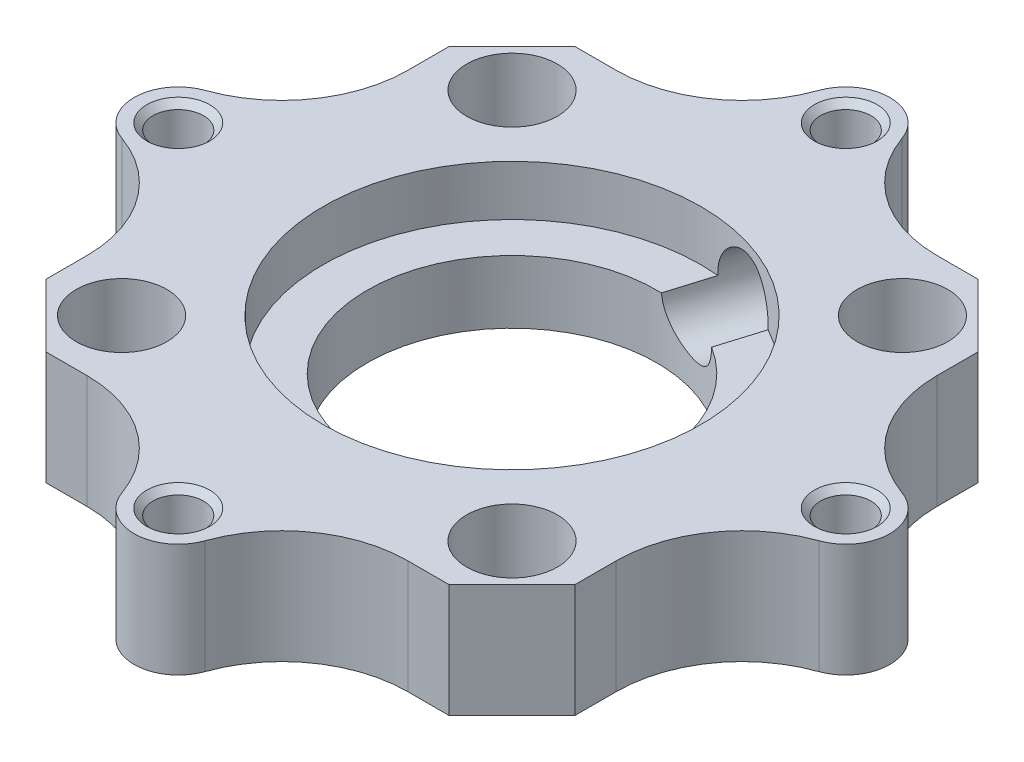
from build123d import *

# Parameters (mm, degrees)
SKETCH1_W               = 60
SKETCH1_H               = 60
SKETCH1_R               = 11.5
BOSS_EXTRUDE1_DEPTH     = 5
CUT_EXTRUDE1_DEPTH      = 10
SKETCH3_R               = 3.6
CUT_EXTRUDE2_DEPTH      = 3
SKETCH4_R               = 1.6
CUT_EXTRUDE3_DEPTH      = 3
SKETCH5_R               = 2
CUT_EXTRUDE4_DEPTH      = 6
CUT_EXTRUDE5_DEPTH      = 6
CHAMFER1_SIZE           = 5
FILLET1_R               = 10
SKETCH7_R               = 2
SKETCH7_R_2             = 3.6
SKETCH7_R_3             = 11.5
BOSS_EXTRUDE2_DEPTH     = 4
SKETCH8_R               = 15
CUT_EXTRUDE6_DEPTH      = 4
SKETCH10_R              = 3
CUT_EXTRUDE7_DEPTH      = 10
CUT_EXTRUDE7_DEPTH_BACK = 16
CHAMFER2_SIZE           = 0.5


with BuildPart() as part:
    # Sketch1 → Boss-Extrude1 (new body)
    with BuildSketch(Plane(origin=(0, 0, 0), x_dir=(1, 0, 0), z_dir=(0, 1, 0))):
        Rectangle(SKETCH1_W, SKETCH1_H)
        Circle(SKETCH1_R, mode=Mode.SUBTRACT)
    extrude(amount=BOSS_EXTRUDE1_DEPTH)

    # Sketch2 → Cut-Extrude1 (cut)
    with BuildSketch(Plane(origin=(0, 5, 0), x_dir=(1, 0, 0), z_dir=(0, 1, 0))):
        with BuildLine():
            Line((-30, 30), (-30, 0))
            ThreePointArc((-30, 0), (-21.21320342, 21.213203451), (4.3e-08, 30))
            Line((4.3e-08, 30), (-30, 30))
        make_face()
        with BuildLine():
            ThreePointArc((4.3e-08, 30), (21.213203451, 21.21320342), (30, 0))
            Line((30, 0), (30, 30))
            Line((30, 30), (4.3e-08, 30))
        make_face()
        with BuildLine():
            Line((0, -30), (30, -30))
            Line((30, -30), (30, 0))
            ThreePointArc((30, 0), (21.213203436, -21.213203436), (0, -30))
        make_face()
        with BuildLine():
            Line((-30, -30), (0, -30))
            ThreePointArc((0, -30), (-21.213203436, -21.213203436), (-30, 0))
            Line((-30, 0), (-30, -30))
        make_face()
    extrude(amount=-CUT_EXTRUDE1_DEPTH, mode=Mode.SUBTRACT)

    # Sketch3 → Cut-Extrude2 (cut)
    with BuildSketch(Plane(origin=(0, 5, 0), x_dir=(1, 0, 0), z_dir=(0, 1, 0))):
        with Locations((-15.5, 15.5)):
            Circle(SKETCH3_R)
        with Locations((15.5, 15.5)):
            Circle(SKETCH3_R)
        with Locations((15.5, -15.5)):
            Circle(SKETCH3_R)
        with Locations((-15.5, -15.5)):
            Circle(SKETCH3_R)
    extrude(amount=-CUT_EXTRUDE2_DEPTH, mode=Mode.SUBTRACT)

    # Sketch4 → Cut-Extrude3 (cut)
    with BuildSketch(Plane(origin=(0, 2, 0), x_dir=(1, 0, 0), z_dir=(0, 1, 0))):
        with Locations((-15.5, 15.5)):
            Circle(SKETCH4_R)
        with Locations((15.5, 15.5)):
            Circle(SKETCH4_R)
        with Locations((15.5, -15.5)):
            Circle(SKETCH4_R)
        with Locations((-15.5, -15.5)):
            Circle(SKETCH4_R)
    extrude(amount=-CUT_EXTRUDE3_DEPTH, mode=Mode.SUBTRACT)

    # Sketch5 → Cut-Extrude4 (cut, through all)
    with BuildSketch(Plane(origin=(0, 5, 0), x_dir=(1, 0, 0), z_dir=(0, 1, 0))):
        with Locations((-26.5, 0)):
            Circle(SKETCH5_R)
        with Locations((0, 26.5)):
            Circle(SKETCH5_R)
        with Locations((26.5, 0)):
            Circle(SKETCH5_R)
        with Locations((0, -26.5)):
            Circle(SKETCH5_R)
    extrude(amount=-CUT_EXTRUDE4_DEPTH, mode=Mode.SUBTRACT)

    # Sketch6 → Cut-Extrude5 (cut, through all)
    with BuildSketch(Plane(origin=(0, 5, 0), x_dir=(1, 0, 0), z_dir=(0, 1, 0))):
        with BuildLine():
            ThreePointArc((-3.5, 26.5), (-2.474873736, 28.974873732), (-5e-09, 30))
            ThreePointArc((-5e-09, 30), (-21.213203437, 21.213203434), (-30, 1e-09))
            ThreePointArc((-30, 1e-09), (-28.974873734, 2.474873735), (-26.5, 3.5))
            Line((-26.5, 3.5), (-21, 3.5))
            Line((-21, 3.5), (-21, 21))
            Line((-21, 21), (-3.5, 21))
            Line((-3.5, 21), (-3.5, 26.5))
        make_face()
        with BuildLine():
            Line((3.5, 26.5), (3.5, 21))
            Line((3.5, 21), (21, 21))
            Line((21, 21), (21, 3.5))
            Line((21, 3.5), (26.5, 3.5))
            ThreePointArc((26.5, 3.5), (28.974873734, 2.474873734), (30, 0))
            ThreePointArc((30, 0), (21.213203434, 21.213203438), (-5e-09, 30))
            ThreePointArc((-5e-09, 30), (2.474873732, 28.974873736), (3.5, 26.5))
        make_face()
        with BuildLine():
            ThreePointArc((-26.5, -3.5), (-28.974873735, -2.474873734), (-30, 1e-09))
            ThreePointArc((-30, 1e-09), (-21.213203436, -21.213203435), (0, -30))
            ThreePointArc((0, -30), (-2.474873734, -28.974873734), (-3.5, -26.5))
            Line((-3.5, -26.5), (-3.5, -21))
            Line((-3.5, -21), (-21, -21))
            Line((-21, -21), (-21, -3.5))
            Line((-21, -3.5), (-26.5, -3.5))
        make_face()
        with BuildLine():
            ThreePointArc((0, -30), (21.213203436, -21.213203436), (30, 0))
            ThreePointArc((30, 0), (28.974873734, -2.474873734), (26.5, -3.5))
            Line((26.5, -3.5), (21, -3.5))
            Line((21, -3.5), (21, -21))
            Line((21, -21), (3.5, -21))
            Line((3.5, -21), (3.5, -26.5))
            ThreePointArc((3.5, -26.5), (2.474873734, -28.974873734), (0, -30))
        make_face()
    extrude(amount=-CUT_EXTRUDE5_DEPTH, mode=Mode.SUBTRACT)

    # Chamfer1
    chamfer1_edges = [part.edges().sort_by_distance(p)[0] for p in [
        (21, 2.5, 21),
        (-21, 2.5, -21),
        (-21, 2.5, 21),
        (21, 2.5, -21),
    ]]
    chamfer(chamfer1_edges, length=CHAMFER1_SIZE)

    # Fillet1
    fillet1_edges = [part.edges().sort_by_distance(p)[0] for p in [
        (3.5, 2.5, -21),
        (-3.5, 2.5, -21),
        (-21, 2.5, -3.5),
        (-21, 2.5, 3.5),
        (-3.5, 2.5, 21),
        (3.5, 2.5, 21),
        (21, 2.5, 3.5),
        (21, 2.5, -3.5),
    ]]
    fillet(fillet1_edges, radius=FILLET1_R)

    # Sketch7 → Boss-Extrude2 (add)
    with BuildSketch(Plane(origin=(0, 5, 0), x_dir=(1, 0, 0), z_dir=(0, 1, 0))):
        with BuildLine():
            Line((-21, -12.727922061), (-21, -16))
            Line((-21, -16), (-16, -21))
            Line((-16, -21), (-12.727922061, -21))
            ThreePointArc((-12.727922061, -21), (-6.954419369, -22.835034191), (-3.299831646, -27.666666667))
            ThreePointArc((-3.299831646, -27.666666667), (0, -30), (3.299831646, -27.666666667))
            ThreePointArc((3.299831646, -27.666666667), (6.954419369, -22.835034191), (12.727922061, -21))
            Line((12.727922061, -21), (16, -21))
            Line((16, -21), (21, -16))
            Line((21, -16), (21, -12.727922061))
            ThreePointArc((21, -12.727922061), (22.835034191, -6.954419369), (27.666666667, -3.299831646))
            ThreePointArc((27.666666667, -3.299831646), (30, 0), (27.666666667, 3.299831646))
            ThreePointArc((27.666666667, 3.299831646), (22.835034191, 6.954419369), (21, 12.727922061))
            Line((21, 12.727922061), (21, 16))
            Line((21, 16), (16, 21))
            Line((16, 21), (12.727922061, 21))
            ThreePointArc((12.727922061, 21), (6.954419369, 22.835034191), (3.299831646, 27.666666667))
            ThreePointArc((3.299831646, 27.666666667), (0, 30), (-3.299831646, 27.666666667))
            ThreePointArc((-3.299831646, 27.666666667), (-6.954419369, 22.835034191), (-12.727922061, 21))
            Line((-12.727922061, 21), (-16, 21))
            Line((-16, 21), (-21, 16))
            Line((-21, 16), (-21, 12.727922061))
            ThreePointArc((-21, 12.727922061), (-22.835034191, 6.954419369), (-27.666666667, 3.299831646))
            ThreePointArc((-27.666666667, 3.299831646), (-30, 0), (-27.666666667, -3.299831646))
            ThreePointArc((-27.666666667, -3.299831646), (-22.835034191, -6.954419369), (-21, -12.727922061))
        make_face()
        with Locations((-26.5, 0)):
            Circle(SKETCH7_R, mode=Mode.SUBTRACT)
        with Locations((0, 26.5)):
            Circle(SKETCH7_R, mode=Mode.SUBTRACT)
        with Locations((26.5, 0)):
            Circle(SKETCH7_R, mode=Mode.SUBTRACT)
        with Locations((0, -26.5)):
            Circle(SKETCH7_R, mode=Mode.SUBTRACT)
        with Locations((-15.5, 15.5)):
            Circle(SKETCH7_R_2, mode=Mode.SUBTRACT)
        with Locations((15.5, 15.5)):
            Circle(SKETCH7_R_2, mode=Mode.SUBTRACT)
        with Locations((15.5, -15.5)):
            Circle(SKETCH7_R_2, mode=Mode.SUBTRACT)
        with Locations((-15.5, -15.5)):
            Circle(SKETCH7_R_2, mode=Mode.SUBTRACT)
        Circle(SKETCH7_R_3, mode=Mode.SUBTRACT)
    extrude(amount=BOSS_EXTRUDE2_DEPTH)

    # Sketch8 → Cut-Extrude6 (cut)
    with BuildSketch(Plane(origin=(0, 9, 0), x_dir=(1, 0, 0), z_dir=(0, 1, 0))):
        Circle(SKETCH8_R)
    extrude(amount=-CUT_EXTRUDE6_DEPTH, mode=Mode.SUBTRACT)

    # Sketch10 → Cut-Extrude7 (cut, two sides)
    with BuildSketch(Plane(origin=(6.806656618, 0, -22.349850985), x_dir=(-0.956619879, 0, -0.291338991), z_dir=(0.291338991, 0, -0.956619879))) as cut_extrude7_sk:
        with Locations((0, 5.23531916)):
            Circle(SKETCH10_R)
    extrude(amount=CUT_EXTRUDE7_DEPTH, mode=Mode.SUBTRACT)
    extrude(cut_extrude7_sk.sketch, amount=-CUT_EXTRUDE7_DEPTH_BACK, mode=Mode.SUBTRACT)

    # Chamfer2
    chamfer2_edges = [part.edges().sort_by_distance(p)[0] for p in [
        (-28.5, 9, 0),
        (-2, 9, -26.5),
        (24.5, 9, 0),
        (-2, 9, 26.5),
    ]]
    chamfer(chamfer2_edges, length=CHAMFER2_SIZE)


solid = part.part
